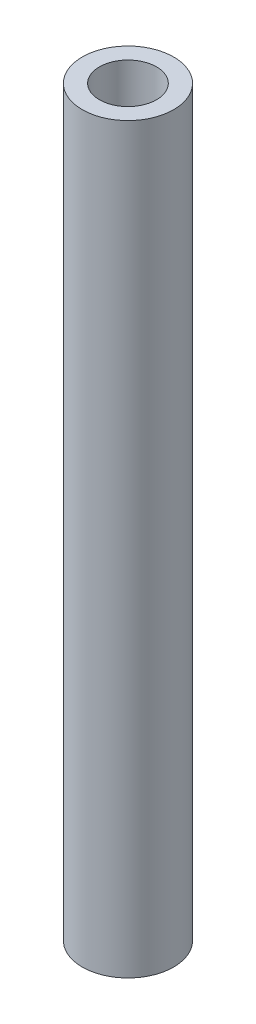
from build123d import *

# Parameters (mm, degrees)
SKETCH1_R           = 4
SKETCH1_R_2         = 2.5
BOSS_EXTRUDE1_DEPTH = 65


with BuildPart() as part:
    # Sketch1 → Boss-Extrude1 (new body)
    with BuildSketch(Plane(origin=(0, 0, 0), x_dir=(1, 0, 0), z_dir=(0, 1, 0))):
        Circle(SKETCH1_R)
        Circle(SKETCH1_R_2, mode=Mode.SUBTRACT)
    extrude(amount=BOSS_EXTRUDE1_DEPTH)


solid = part.part
